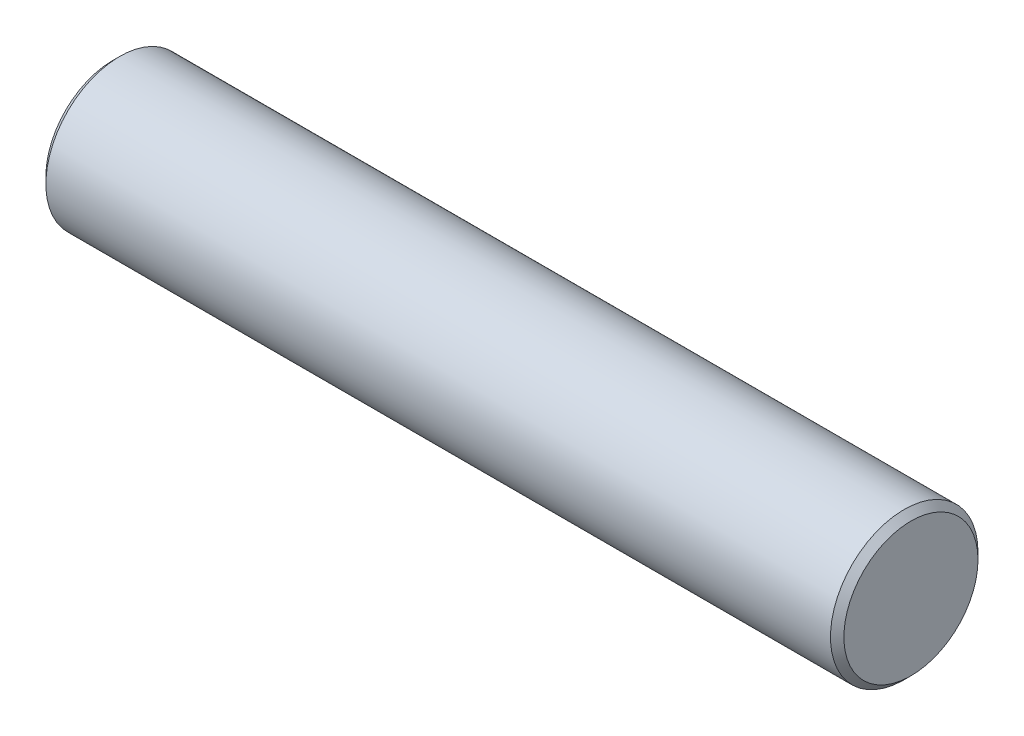
from build123d import *

# Parameters (mm, degrees)
SKETCH1_R           = 11
BOSS_EXTRUDE1_DEPTH = 59.5
CHAMFER1_SIZE       = 1


with BuildPart() as part:
    # Sketch1 → Boss-Extrude1 (new body, symmetric)
    with BuildSketch(Plane(origin=(0, 0, 0), x_dir=(0, 0, -1), z_dir=(1, 0, 0))):
        Circle(SKETCH1_R)
    extrude(amount=BOSS_EXTRUDE1_DEPTH, both=True)

    # Chamfer1
    chamfer1_edges = [part.edges().sort_by_distance(p)[0] for p in [
        (-59.5, 0, 11),
        (59.5, 0, 11),
    ]]
    chamfer(chamfer1_edges, length=CHAMFER1_SIZE)


solid = part.part
